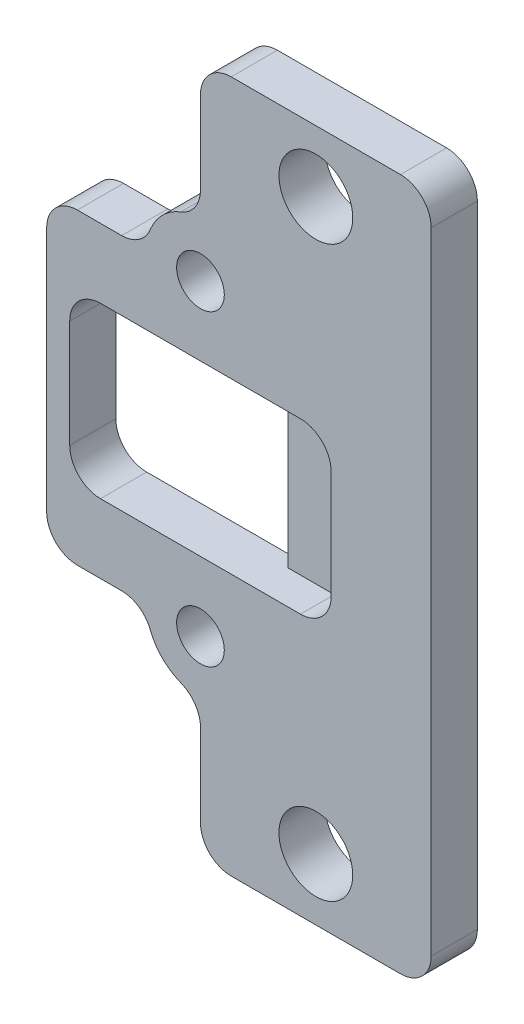
from build123d import *

# Parameters (mm, degrees)
EXTRUDE_1_DEPTH    = 3
HOLE_WIZARD_M4_1_D = 4.8
SKETCH_5_W         = 5
SKETCH_5_H         = 11
EXTRUDE_2_DEPTH    = 0.8
FILLET_6_R         = 2


with BuildPart() as part:
    # ｽｹｯﾁ1 → ﾎﾞｽ - 押し出し1 (new body)
    with BuildSketch(Plane(origin=(0, 0, 0), x_dir=(0, 1, 0), z_dir=(0, 0, 1))):
        with BuildLine():
            Line((-22.5, 7.5), (-22.5, -7.5))
            Line((-22.5, -7.5), (22.5, -7.5))
            Line((22.5, -7.5), (22.5, 7.5))
            Line((22.5, 7.5), (13.5, 7.5))
            ThreePointArc((13.5, 7.5), (10, 4), (6.5, 7.5))
            Line((6.5, 7.5), (5.5, 7.5))
            Line((5.5, 7.5), (5.5, -1))
            Line((5.5, -1), (-5.5, -1))
            Line((-5.5, -1), (-5.5, 7.5))
            Line((-5.5, 7.5), (-6.5, 7.5))
            ThreePointArc((-6.5, 7.5), (-10, 4), (-13.5, 7.5))
            Line((-13.5, 7.5), (-22.5, 7.5))
        make_face()
        with BuildLine():
            Line((-10, 17.5), (-10, 11))
            ThreePointArc((-10, 11), (-7.525126266, 9.974873734), (-6.5, 7.5))
            Line((-6.5, 7.5), (-5.5, 7.5))
            Line((-5.5, 7.5), (-5.5, 16))
            Line((-5.5, 16), (5.5, 16))
            Line((5.5, 16), (5.5, 7.5))
            Line((5.5, 7.5), (6.5, 7.5))
            ThreePointArc((6.5, 7.5), (7.525126266, 9.974873734), (10, 11))
            Line((10, 11), (10, 17.5))
            Line((10, 17.5), (-10, 17.5))
        make_face()
        with BuildLine():
            ThreePointArc((-6.5, 7.5), (-7.525126266, 9.974873734), (-10, 11))
            Line((-10, 11), (-10, 9.05))
            ThreePointArc((-10, 9.05), (-8.903984489, 8.596015511), (-8.45, 7.5))
            Line((-8.45, 7.5), (-6.5, 7.5))
        make_face()
        with BuildLine():
            ThreePointArc((-10, 11), (-12.474873734, 9.974873734), (-13.5, 7.5))
            Line((-13.5, 7.5), (-11.55, 7.5))
            ThreePointArc((-11.55, 7.5), (-11.096015511, 8.596015511), (-10, 9.05))
            Line((-10, 9.05), (-10, 11))
        make_face()
        with BuildLine():
            Line((-11.55, 7.5), (-13.5, 7.5))
            ThreePointArc((-13.5, 7.5), (-10, 4), (-6.5, 7.5))
            Line((-6.5, 7.5), (-8.45, 7.5))
            ThreePointArc((-8.45, 7.5), (-10, 5.95), (-11.55, 7.5))
        make_face()
        with BuildLine():
            Line((10, 9.05), (10, 11))
            ThreePointArc((10, 11), (7.525126266, 9.974873734), (6.5, 7.5))
            Line((6.5, 7.5), (8.45, 7.5))
            ThreePointArc((8.45, 7.5), (8.903984489, 8.596015511), (10, 9.05))
        make_face()
        with BuildLine():
            Line((11.55, 7.5), (13.5, 7.5))
            ThreePointArc((13.5, 7.5), (12.474873734, 9.974873734), (10, 11))
            Line((10, 11), (10, 9.05))
            ThreePointArc((10, 9.05), (11.096015511, 8.596015511), (11.55, 7.5))
        make_face()
        with BuildLine():
            ThreePointArc((6.5, 7.5), (10, 4), (13.5, 7.5))
            Line((13.5, 7.5), (11.55, 7.5))
            ThreePointArc((11.55, 7.5), (10, 5.95), (8.45, 7.5))
            Line((8.45, 7.5), (6.5, 7.5))
        make_face()
    extrude(amount=EXTRUDE_1_DEPTH)

    # M4 すきま穴1 (through all)
    with Locations(Plane.XY.offset(3)):
        with Locations((0, -18.5), (0, 18.5)):
            Hole(HOLE_WIZARD_M4_1_D / 2)

    # ｽｹｯﾁ5 → ﾎﾞｽ - 押し出し2 (add)
    with BuildSketch(Plane(origin=(0, 0, 0), x_dir=(1, 0, 0), z_dir=(0, 0, -1))):
        with Locations((-1.5, 0)):
            Rectangle(SKETCH_5_W, SKETCH_5_H)
    extrude(amount=-EXTRUDE_2_DEPTH)

    # ﾌｨﾚｯﾄ6
    fillet_6_edges = [part.edges().sort_by_distance(p)[0] for p in [
        (-16, -5.5, 1.5),
        (1, -5.5, 1.9),
        (1, 5.5, 1.9),
        (-16, 5.5, 1.5),
        (-7.5, 13.5, 1.5),
        (-7.5, 22.5, 1.5),
        (7.5, 22.5, 1.5),
        (7.5, -22.5, 1.5),
        (-7.5, -22.5, 1.5),
        (-7.5, -13.5, 1.5),
        (-11, -10, 1.5),
        (-17.5, -10, 1.5),
        (-17.5, 10, 1.5),
        (-11, 10, 1.5),
    ]]
    fillet(fillet_6_edges, radius=FILLET_6_R)


solid = part.part
